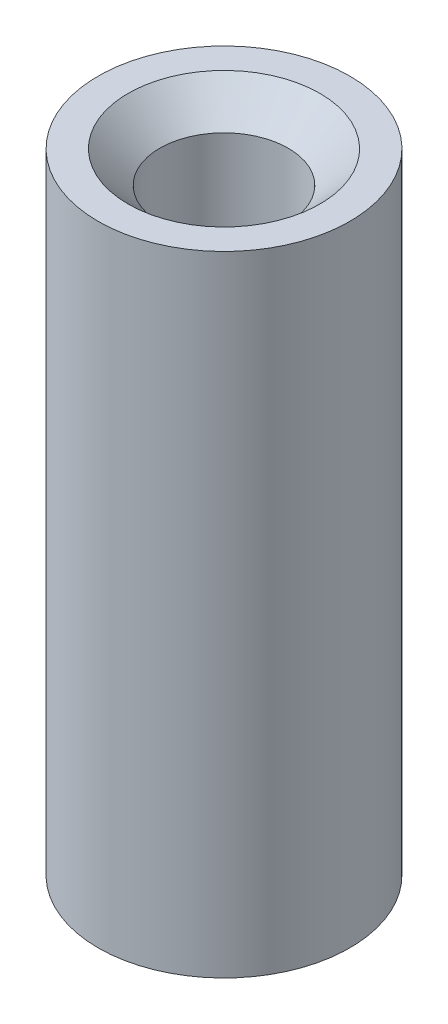
from build123d import *

# Parameters (mm, degrees)
SKETCH1_R                         = 5
BOSS_EXTRUDE1_DEPTH               = 25
F_1_4_20_TAPPED_HOLE1_D           = 5.1054
F_1_4_20_TAPPED_HOLE1_CSINK_D     = 7.62
F_1_4_20_TAPPED_HOLE1_CSINK_ANGLE = 90


with BuildPart() as part:
    # Sketch1 → Boss-Extrude1 (new body)
    with BuildSketch(Plane(origin=(0, 0, 0), x_dir=(1, 0, 0), z_dir=(0, 1, 0))):
        Circle(SKETCH1_R)
    extrude(amount=-BOSS_EXTRUDE1_DEPTH)

    # 1/4-20 Tapped Hole1 (through all)
    with Locations(Plane(origin=(0, 0, 0), x_dir=(1, 0, 0), z_dir=(0, 1, 0))):
        with Locations((0, 0)):
            CounterSinkHole(F_1_4_20_TAPPED_HOLE1_D / 2, F_1_4_20_TAPPED_HOLE1_CSINK_D / 2, counter_sink_angle=F_1_4_20_TAPPED_HOLE1_CSINK_ANGLE)


solid = part.part
